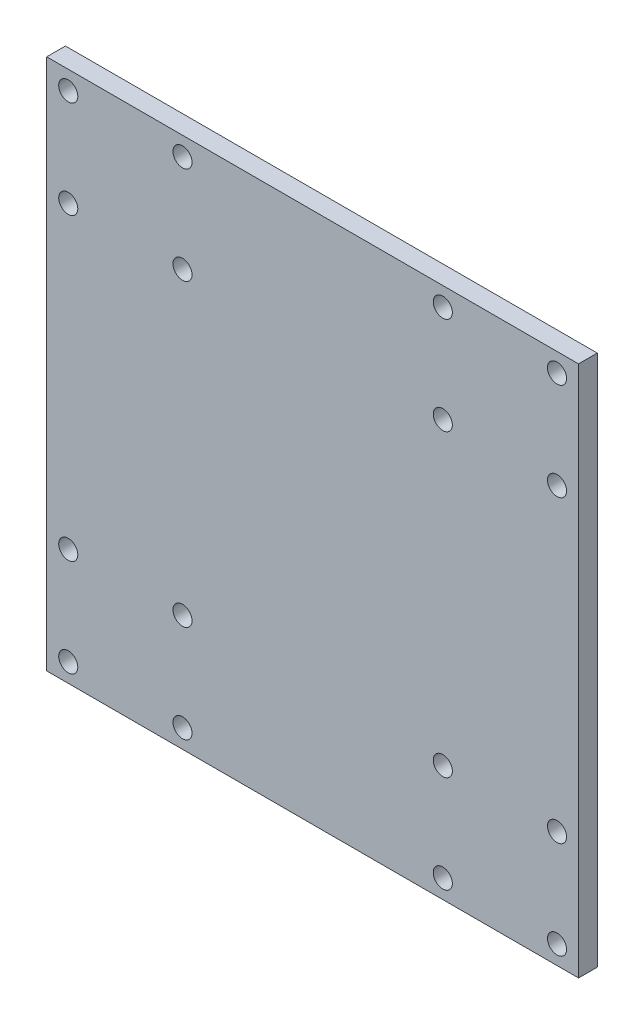
from build123d import *

# Parameters (mm, degrees)
SKETCH1_W           = 142
SKETCH1_H           = 142
BOSS_EXTRUDE1_DEPTH = 2.5
SKETCH2_R           = 2.55
CUT_EXTRUDE1_DEPTH  = 6


with BuildPart() as part:
    # Sketch1 → Boss-Extrude1 (new body, symmetric)
    with BuildSketch(Plane.XY):
        Rectangle(SKETCH1_W, SKETCH1_H)
    extrude(amount=BOSS_EXTRUDE1_DEPTH, both=True)

    # Sketch2 → Cut-Extrude1 (cut, through all)
    with BuildSketch(Plane.XY.offset(2.5)):
        with Locations((-65.25, 66)):
            Circle(SKETCH2_R)
        with Locations((-34.75, 66)):
            Circle(SKETCH2_R)
        with Locations((-34.75, 40)):
            Circle(SKETCH2_R)
        with Locations((-65.25, 40)):
            Circle(SKETCH2_R)
        with Locations((65.25, 66)):
            Circle(SKETCH2_R)
        with Locations((65.25, 40)):
            Circle(SKETCH2_R)
        with Locations((34.75, 40)):
            Circle(SKETCH2_R)
        with Locations((34.75, 66)):
            Circle(SKETCH2_R)
        with Locations((-65.25, -40)):
            Circle(SKETCH2_R)
        with Locations((-34.75, -40)):
            Circle(SKETCH2_R)
        with Locations((-34.75, -66)):
            Circle(SKETCH2_R)
        with Locations((-65.25, -66)):
            Circle(SKETCH2_R)
        with Locations((34.75, -40)):
            Circle(SKETCH2_R)
        with Locations((65.25, -40)):
            Circle(SKETCH2_R)
        with Locations((65.25, -66)):
            Circle(SKETCH2_R)
        with Locations((34.75, -66)):
            Circle(SKETCH2_R)
    extrude(amount=-CUT_EXTRUDE1_DEPTH, mode=Mode.SUBTRACT)


solid = part.part
